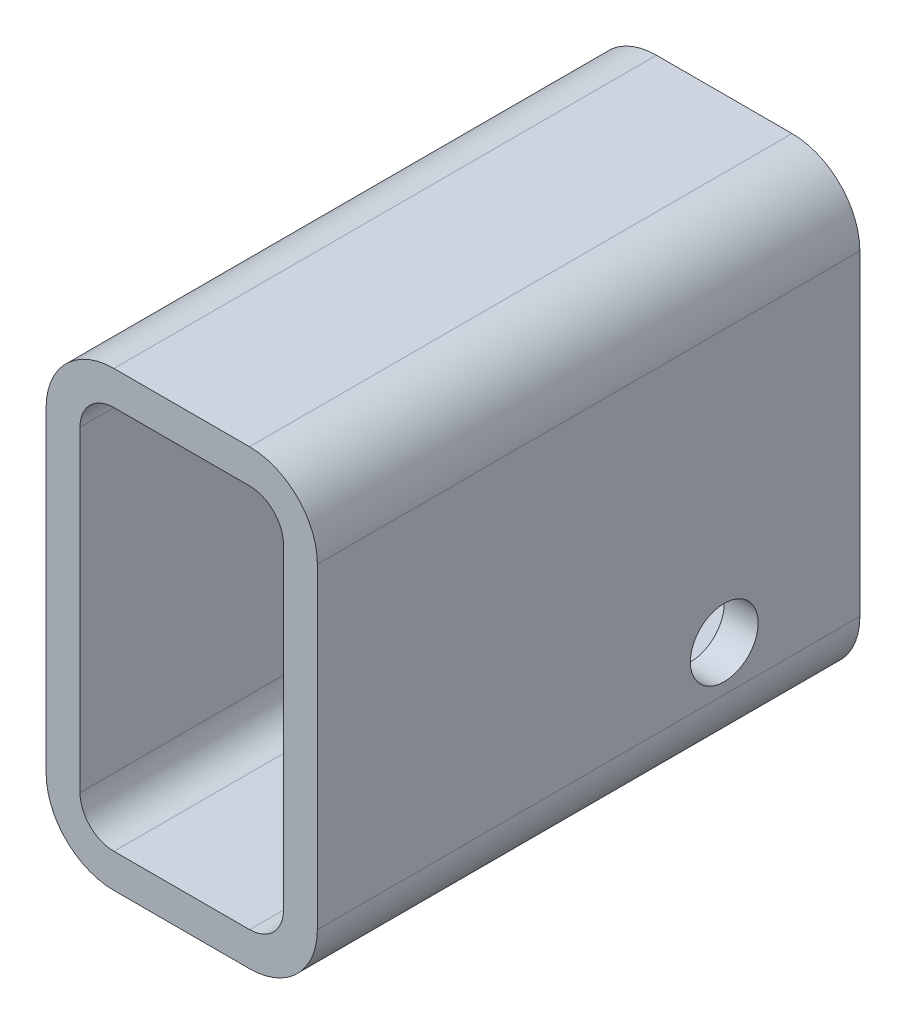
from build123d import *

# Parameters (mm, degrees)
BASETUBER_DEPTH    = 76.2
CUT_EXTRUDE2_REACH = 78.2
SKETCH3_R          = 9.525


with BuildPart() as part:
    # Sketch1 → BaseTubeR (new body, symmetric)
    with BuildSketch(Plane.XY):
        with BuildLine():
            Line((19.05, 0), (57.15, 0))
            ThreePointArc((57.15, 0), (70.620384182, 5.579615818), (76.2, 19.05))
            Line((76.2, 19.05), (76.2, 107.95))
            ThreePointArc((76.2, 107.95), (70.620384182, 121.420384182), (57.15, 127))
            Line((57.15, 127), (19.05, 127))
            ThreePointArc((19.05, 127), (5.579615818, 121.420384182), (0, 107.95))
            Line((0, 107.95), (0, 19.05))
            ThreePointArc((0, 19.05), (5.579615818, 5.579615818), (19.05, 0))
        make_face()
        with BuildLine():
            Line((19.05, 9.525), (57.15, 9.525))
            ThreePointArc((57.15, 9.525), (63.885192091, 12.314807909), (66.675, 19.05))
            Line((66.675, 19.05), (66.675, 107.95))
            ThreePointArc((66.675, 107.95), (63.885192091, 114.685192091), (57.15, 117.475))
            Line((57.15, 117.475), (19.05, 117.475))
            ThreePointArc((19.05, 117.475), (12.314807909, 114.685192091), (9.525, 107.95))
            Line((9.525, 107.95), (9.525, 19.05))
            ThreePointArc((9.525, 19.05), (12.314807909, 12.314807909), (19.05, 9.525))
        make_face(mode=Mode.SUBTRACT)
    extrude(amount=BASETUBER_DEPTH, both=True)

    # Sketch3 → Cut-Extrude2 (cut, up to next)
    with BuildSketch(Plane(origin=(76.2, 0, 0), x_dir=(0, 0, -1), z_dir=(1, 0, 0)), mode=Mode.PRIVATE) as cut_extrude2_sk1:
        with Locations((38.1, 31.75)):
            Circle(SKETCH3_R)
    cut_extrude2_tool1 = extrude(cut_extrude2_sk1.sketch, amount=-CUT_EXTRUDE2_REACH, mode=Mode.PRIVATE) & part.part
    add(cut_extrude2_tool1.solids().sort_by_distance((76.2, 31.75, -38.1))[0], mode=Mode.SUBTRACT)


solid = part.part
